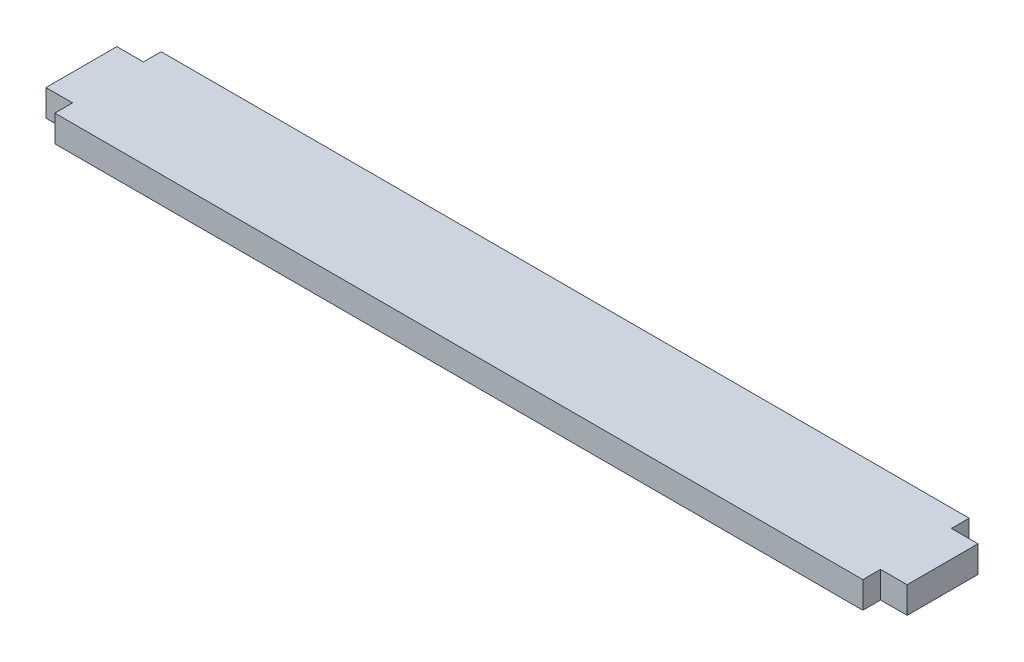
from build123d import *

# Parameters (mm, degrees)
BOSS_EXTRUDE1_DEPTH = 3


with BuildPart() as part:
    # Sketch1 → Boss-Extrude1 (new body)
    with BuildSketch(Plane(origin=(0, 0, 0), x_dir=(1, 0, 0), z_dir=(0, 1, 0))):
        Polygon((-45.6, 6), (-45.6, 4), (-48.6, 4), (-48.6, -4), (-45.6, -4), (-45.6, -6), (45.6, -6), (45.6, -4), (48.6, -4), (48.6, 4), (45.6, 4), (45.6, 6), align=None)
    extrude(amount=BOSS_EXTRUDE1_DEPTH)


solid = part.part
